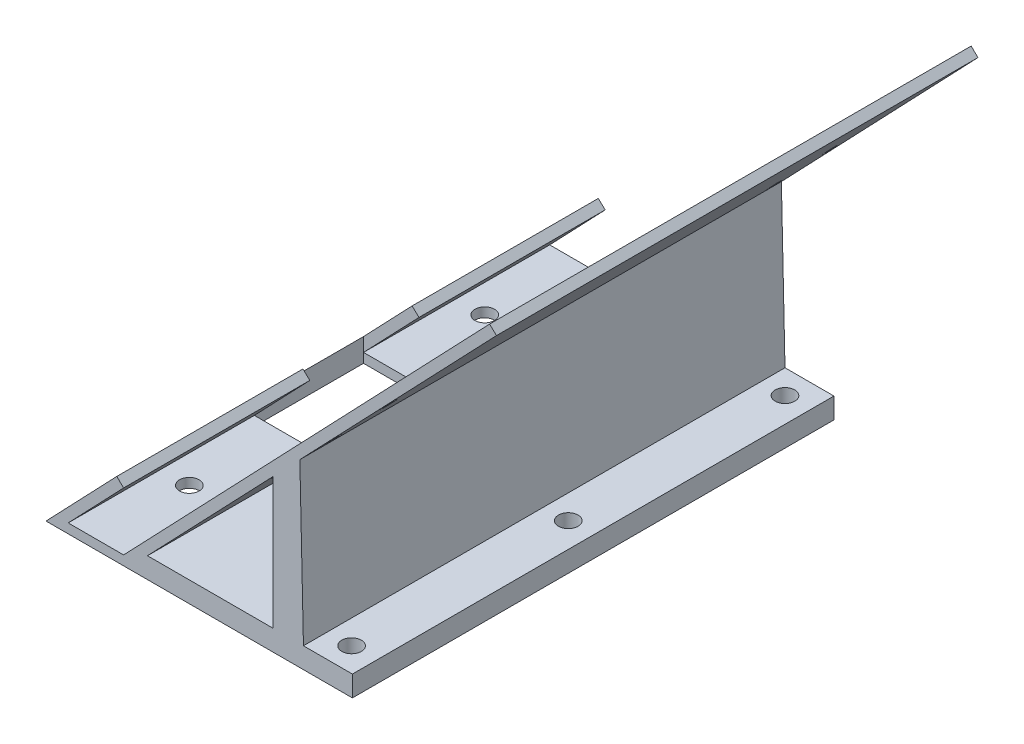
from build123d import *

# Parameters (mm, degrees)
BOSS_EXTRUDE1_DEPTH = 76.2
SKETCH3_W           = 8.774879522
SKETCH3_H           = 8.636
CUT_EXTRUDE1_DEPTH  = 33.02
SKETCH5_W           = 1.27
SKETCH5_H           = 2.54
CUT_EXTRUDE2_DEPTH  = 1.5
BOSS_EXTRUDE2_DEPTH = 76.2
SKETCH7_R           = 1.55
CUT_EXTRUDE3_DEPTH  = 3.2766
SKETCH9_R           = 1.55
CUT_EXTRUDE4_DEPTH  = 1.5


with BuildPart() as part:
    # Sketch1 → Boss-Extrude1 (new body)
    with BuildSketch(Plane.XY):
        Polygon((3.772933373, -7.404439667), (0.641286927, -10.681039667), (36.201286927, -10.681039667), (36.201286927, -7.404439667), align=None)
        Polygon((57.914204847, 51.413822136), (58.998579611, 50.377419043), (0.641286927, -10.681039667), (-12.283449407, -10.681039667), (-1.084374764, 1.036403093), (0, 0), (-8.774879522, -9.181039667), (0, -9.181039667), align=None)
    extrude(amount=BOSS_EXTRUDE1_DEPTH)

    # Sketch3 → Cut-Extrude1 (cut, symmetric)
    with BuildSketch(Plane(origin=(0, -9.181039667, 0), x_dir=(1, 0, 0), z_dir=(0, 1, 0))):
        with Locations((-4.387439761, -42.418)):
            Rectangle(SKETCH3_W, SKETCH3_H)
        with Locations((-4.387439761, -33.782)):
            Rectangle(SKETCH3_W, SKETCH3_H)
    extrude(amount=CUT_EXTRUDE1_DEPTH, both=True, mode=Mode.SUBTRACT)

    # Sketch5 → Cut-Extrude2 (cut)
    with BuildSketch(Plane(origin=(4.585824688, -4.382952324, 0), x_dir=(0, 0, 1), z_dir=(-0.722916509, 0.690935395, 0))):
        with Locations((3.175, 22.572874853)):
            Rectangle(SKETCH5_W, SKETCH5_H)
        with Locations((3.175, 35.272874853)):
            Rectangle(SKETCH5_W, SKETCH5_H)
        with Locations((3.175, 47.972874853)):
            Rectangle(SKETCH5_W, SKETCH5_H)
        with Locations((73.025, 22.572874853)):
            Rectangle(SKETCH5_W, SKETCH5_H)
        with Locations((73.025, 35.272874853)):
            Rectangle(SKETCH5_W, SKETCH5_H)
        with Locations((73.025, 47.972874853)):
            Rectangle(SKETCH5_W, SKETCH5_H)
    extrude(amount=-CUT_EXTRUDE2_DEPTH, mode=Mode.SUBTRACT)

    # Sketch6 → Boss-Extrude2 (add)
    with BuildSketch(Plane.XY.offset(76.2)):
        Polygon((23.628168528, -7.404439667), (23.628168528, 13.36982864), (27.885054397, 17.823751673), (28.455712225, -7.404439667), align=None)
    extrude(amount=-BOSS_EXTRUDE2_DEPTH)

    # Sketch7 → Cut-Extrude3 (cut)
    with BuildSketch(Plane(origin=(0, -7.404439667, 0), x_dir=(1, 0, 0), z_dir=(0, 1, 0))):
        with Locations((32.265712225, -72.39)):
            Circle(SKETCH7_R)
        with Locations((32.265712225, -3.81)):
            Circle(SKETCH7_R)
        with Locations((32.265712225, -38.1)):
            Circle(SKETCH7_R)
    extrude(amount=-CUT_EXTRUDE3_DEPTH, mode=Mode.SUBTRACT)

    # Sketch9 → Cut-Extrude4 (cut)
    with BuildSketch(Plane(origin=(0, -9.181039667, 0), x_dir=(1, 0, 0), z_dir=(0, 1, 0))):
        with Locations((-4.329879522, -61.468)):
            Circle(SKETCH9_R)
        with Locations((-4.329879522, -14.732)):
            Circle(SKETCH9_R)
    extrude(amount=-CUT_EXTRUDE4_DEPTH, mode=Mode.SUBTRACT)


solid = part.part
